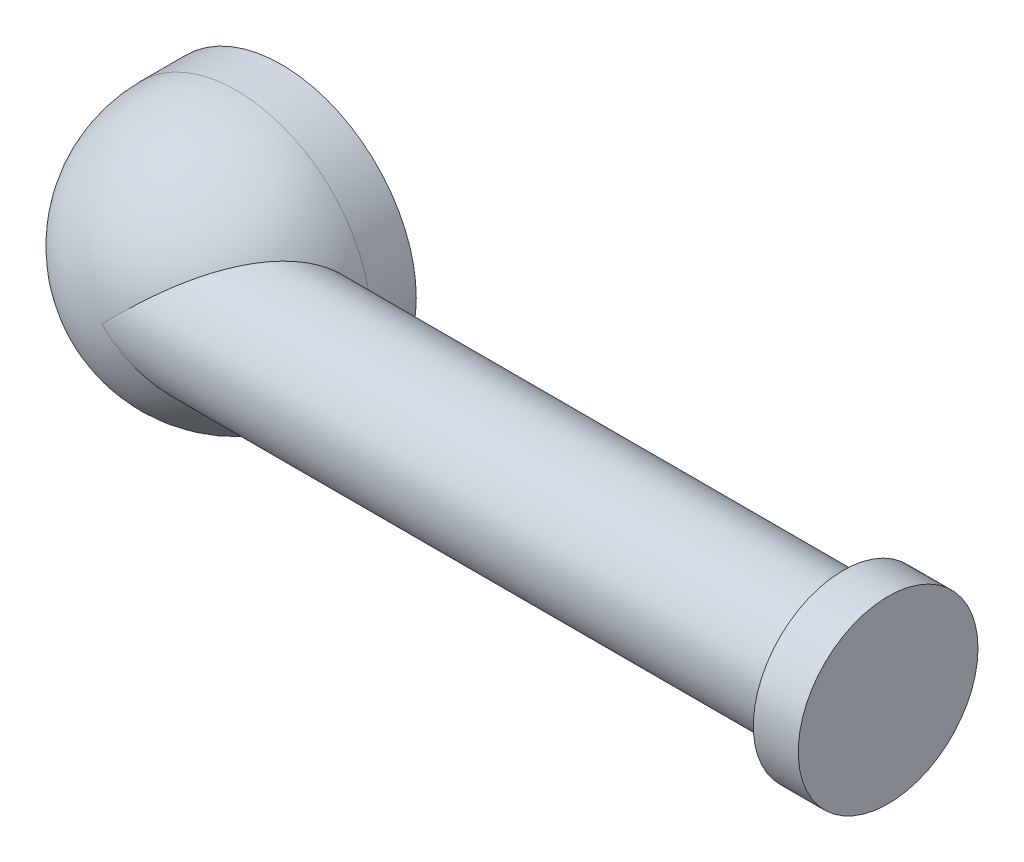
from build123d import *

# Parameters (mm, degrees)
SKETCH_1_R      = 3
SKETCH_1_R_2    = 2
EXTRUDE_1_DEPTH = 1
SKETCH_4_R      = 1.5
EXTRUDE_2_DEPTH = 15
SKETCH_5_R      = 2
EXTRUDE_3_DEPTH = 1


with BuildPart() as part:
    # 草图1 → 凸台-拉伸1 (new body)
    with BuildSketch(Plane.XY):
        Circle(SKETCH_1_R)
        Circle(SKETCH_1_R_2, mode=Mode.SUBTRACT)
    extrude(amount=EXTRUDE_1_DEPTH)

    # 草图2 → 旋转3 (revolve)
    with BuildSketch(Plane(origin=(0, 0, 0), x_dir=(1, 0, 0), z_dir=(0, 1, 0))):
        with BuildLine():
            Line((0, -4), (0, -1))
            Line((0, -1), (3, -1))
            ThreePointArc((3, -1), (2.121320344, -3.121320344), (0, -4))
        make_face()
    revolve(axis=Axis((0, 0, 4), (0, 0, 1)))

    # 草图4 → 凸台-拉伸2 (add)
    with BuildSketch(Plane(origin=(0, 0, 0), x_dir=(0, 0, -1), z_dir=(1, 0, 0))):
        with Locations((-2.5, 0)):
            Circle(SKETCH_4_R)
    extrude(amount=EXTRUDE_2_DEPTH)


with BuildPart() as body_2:
    # 草图5 → 凸台-拉伸3 (new body)
    with BuildSketch(Plane(origin=(15, 0, 0), x_dir=(0, 0, -1), z_dir=(1, 0, 0))):
        with Locations((-2.5, 0)):
            Circle(SKETCH_5_R)
    extrude(amount=EXTRUDE_3_DEPTH)


solid = Compound([part.part, body_2.part])
